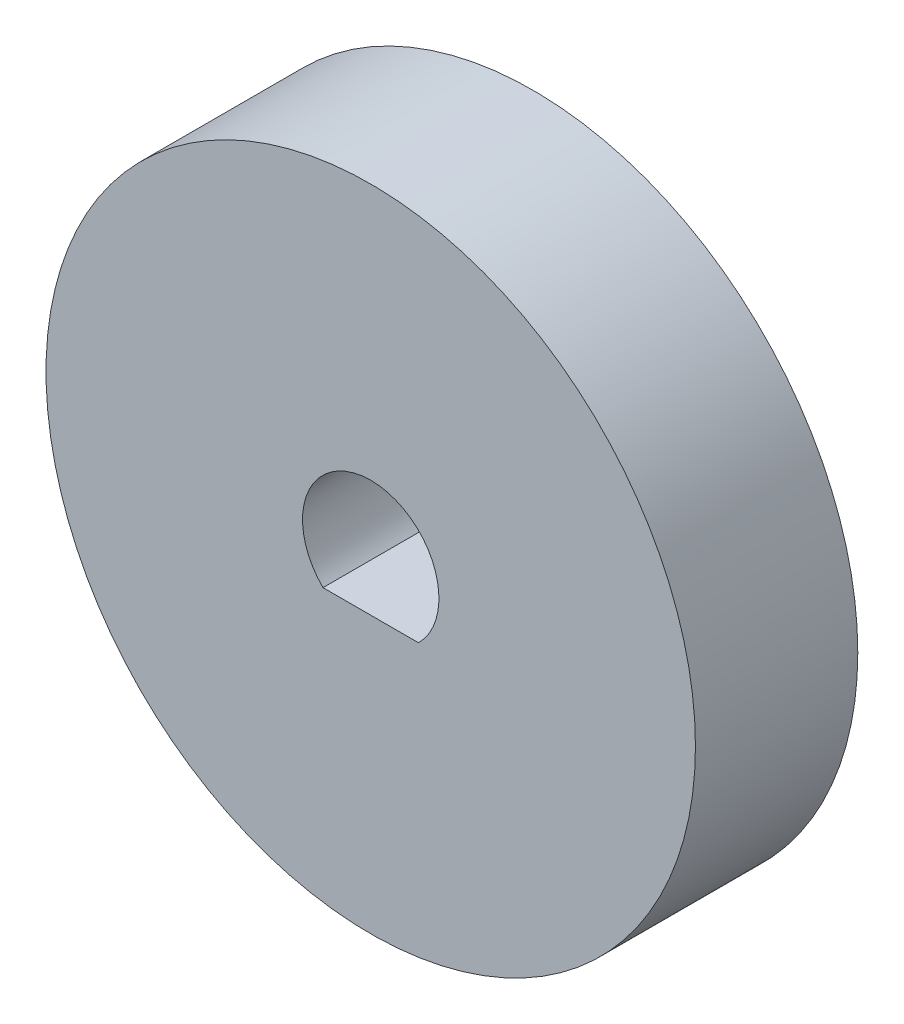
from build123d import *

# Parameters (mm, degrees)
SKETCH_1_R          = 10
EXTRUDE_2_DEPTH     = 5
CUT_EXTRUDE_1_DEPTH = 5


with BuildPart() as part:
    # Эскиз1 → Бобышка-Вытянуть2 (new body)
    with BuildSketch(Plane.XY):
        Circle(SKETCH_1_R)
    extrude(amount=EXTRUDE_2_DEPTH)

    # Эскиз3 → Вырез-Вытянуть1 (cut)
    with BuildSketch(Plane.XY.offset(5)):
        with BuildLine():
            Line((1.469693846, -1.5), (-1.469693846, -1.5))
            ThreePointArc((-1.469693846, -1.5), (0, 2.1), (1.469693846, -1.5))
        make_face()
    extrude(amount=-CUT_EXTRUDE_1_DEPTH, mode=Mode.SUBTRACT)


solid = part.part
